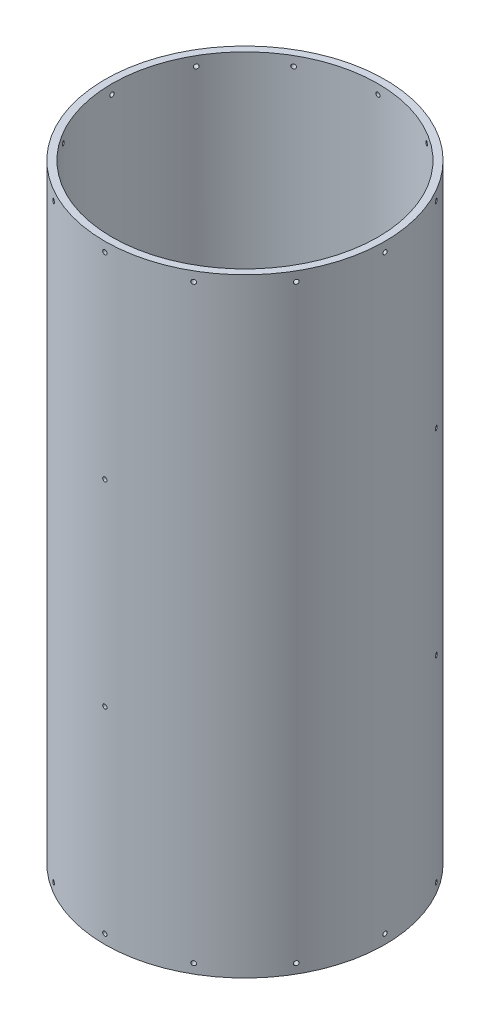
from build123d import *

# Parameters (mm, degrees)
SKETCH1_R                = 93.6625
SKETCH1_R_2              = 88.9
BOSS_EXTRUDE1_DEPTH      = 203.581
SKETCH3_R                = 1.4351
CUT_EXTRUDE1_DEPTH       = 19.304
CIRPATTERN1_COUNT        = 12
MIRROR1_COPY_1_SKETCH_R  = 1.4351
MIRROR1_COPY_1_DEPTH     = 19.304
MIRROR1_COPY_2_SKETCH_R  = 1.4351
MIRROR1_COPY_2_DEPTH     = 19.304
MIRROR1_COPY_3_SKETCH_R  = 1.4351
MIRROR1_COPY_3_DEPTH     = 19.304
MIRROR1_COPY_4_SKETCH_R  = 1.4351
MIRROR1_COPY_4_DEPTH     = 19.304
MIRROR1_COPY_5_SKETCH_R  = 1.4351
MIRROR1_COPY_5_DEPTH     = 19.304
MIRROR1_COPY_6_SKETCH_R  = 1.4351
MIRROR1_COPY_6_DEPTH     = 19.304
MIRROR1_COPY_7_SKETCH_R  = 1.4351
MIRROR1_COPY_7_DEPTH     = 19.304
MIRROR1_COPY_8_SKETCH_R  = 1.4351
MIRROR1_COPY_8_DEPTH     = 19.304
MIRROR1_COPY_9_SKETCH_R  = 1.4351
MIRROR1_COPY_9_DEPTH     = 19.304
MIRROR1_COPY_10_SKETCH_R = 1.4351
MIRROR1_COPY_10_DEPTH    = 19.304
MIRROR1_COPY_11_SKETCH_R = 1.4351
MIRROR1_COPY_11_DEPTH    = 19.304
SKETCH4_R                = 1.4351
CUT_EXTRUDE2_DEPTH       = 43.18
CIRPATTERN2_COUNT        = 3


with BuildPart() as part:
    # Sketch1 → Boss-Extrude1 (new body, symmetric)
    with BuildSketch(Plane(origin=(0, 0, 0), x_dir=(1, 0, 0), z_dir=(0, 1, 0))):
        Circle(SKETCH1_R)
        Circle(SKETCH1_R_2, mode=Mode.SUBTRACT)
    extrude(amount=BOSS_EXTRUDE1_DEPTH, both=True)

    # Sketch3 → Cut-Extrude1 (cut)
    with BuildSketch(Plane.XY.offset(93.6625)):
        with Locations((0, -197.231)):
            Circle(SKETCH3_R)
    cut_extrude1 = extrude(amount=-CUT_EXTRUDE1_DEPTH, mode=Mode.SUBTRACT)

    # CirPattern1: Cut-Extrude1 ×12 about axis
    cirpattern1_axis = Axis((0, 203.581, 0), (0, -1, 0))
    for i in range(1, CIRPATTERN1_COUNT):
        add(cut_extrude1.rotate(cirpattern1_axis, i * 360 / CIRPATTERN1_COUNT), mode=Mode.SUBTRACT)

    # Mirror1: Cut-Extrude1 across plane
    add(cut_extrude1.mirror(Plane.ZX), mode=Mode.SUBTRACT)

    # Mirror1 copy 1 sketch → Mirror1 copy 1 (cut)
    with BuildSketch(Plane(origin=(-46.83125, 0, 81.114104382), x_dir=(0.866025404, 0, 0.5), z_dir=(-0.5, 0, 0.866025404))):
        with Locations((0, 197.231)):
            Circle(MIRROR1_COPY_1_SKETCH_R)
    extrude(amount=-MIRROR1_COPY_1_DEPTH, mode=Mode.SUBTRACT)

    # Mirror1 copy 2 sketch → Mirror1 copy 2 (cut)
    with BuildSketch(Plane(origin=(-81.114104382, 0, 46.83125), x_dir=(0.5, 0, 0.866025404), z_dir=(-0.866025404, 0, 0.5))):
        with Locations((0, 197.231)):
            Circle(MIRROR1_COPY_2_SKETCH_R)
    extrude(amount=-MIRROR1_COPY_2_DEPTH, mode=Mode.SUBTRACT)

    # Mirror1 copy 3 sketch → Mirror1 copy 3 (cut)
    with BuildSketch(Plane.ZY.offset(93.6625)):
        with Locations((0, 197.231)):
            Circle(MIRROR1_COPY_3_SKETCH_R)
    extrude(amount=-MIRROR1_COPY_3_DEPTH, mode=Mode.SUBTRACT)

    # Mirror1 copy 4 sketch → Mirror1 copy 4 (cut)
    with BuildSketch(Plane(origin=(-81.114104382, 0, -46.83125), x_dir=(-0.5, 0, 0.866025404), z_dir=(-0.866025404, 0, -0.5))):
        with Locations((0, 197.231)):
            Circle(MIRROR1_COPY_4_SKETCH_R)
    extrude(amount=-MIRROR1_COPY_4_DEPTH, mode=Mode.SUBTRACT)

    # Mirror1 copy 5 sketch → Mirror1 copy 5 (cut)
    with BuildSketch(Plane(origin=(-46.83125, 0, -81.114104382), x_dir=(-0.866025404, 0, 0.5), z_dir=(-0.5, 0, -0.866025404))):
        with Locations((0, 197.231)):
            Circle(MIRROR1_COPY_5_SKETCH_R)
    extrude(amount=-MIRROR1_COPY_5_DEPTH, mode=Mode.SUBTRACT)

    # Mirror1 copy 6 sketch → Mirror1 copy 6 (cut)
    with BuildSketch(Plane(origin=(0, 0, -93.6625), x_dir=(-1, 0, 0), z_dir=(0, 0, -1))):
        with Locations((0, 197.231)):
            Circle(MIRROR1_COPY_6_SKETCH_R)
    extrude(amount=-MIRROR1_COPY_6_DEPTH, mode=Mode.SUBTRACT)

    # Mirror1 copy 7 sketch → Mirror1 copy 7 (cut)
    with BuildSketch(Plane(origin=(46.83125, 0, -81.114104382), x_dir=(-0.866025404, 0, -0.5), z_dir=(0.5, 0, -0.866025404))):
        with Locations((0, 197.231)):
            Circle(MIRROR1_COPY_7_SKETCH_R)
    extrude(amount=-MIRROR1_COPY_7_DEPTH, mode=Mode.SUBTRACT)

    # Mirror1 copy 8 sketch → Mirror1 copy 8 (cut)
    with BuildSketch(Plane(origin=(81.114104382, 0, -46.83125), x_dir=(-0.5, 0, -0.866025404), z_dir=(0.866025404, 0, -0.5))):
        with Locations((0, 197.231)):
            Circle(MIRROR1_COPY_8_SKETCH_R)
    extrude(amount=-MIRROR1_COPY_8_DEPTH, mode=Mode.SUBTRACT)

    # Mirror1 copy 9 sketch → Mirror1 copy 9 (cut)
    with BuildSketch(Plane(origin=(93.6625, 0, 0), x_dir=(0, 0, -1), z_dir=(1, 0, 0))):
        with Locations((0, 197.231)):
            Circle(MIRROR1_COPY_9_SKETCH_R)
    extrude(amount=-MIRROR1_COPY_9_DEPTH, mode=Mode.SUBTRACT)

    # Mirror1 copy 10 sketch → Mirror1 copy 10 (cut)
    with BuildSketch(Plane(origin=(81.114104382, 0, 46.83125), x_dir=(0.5, 0, -0.866025404), z_dir=(0.866025404, 0, 0.5))):
        with Locations((0, 197.231)):
            Circle(MIRROR1_COPY_10_SKETCH_R)
    extrude(amount=-MIRROR1_COPY_10_DEPTH, mode=Mode.SUBTRACT)

    # Mirror1 copy 11 sketch → Mirror1 copy 11 (cut)
    with BuildSketch(Plane(origin=(46.83125, 0, 81.114104382), x_dir=(0.866025404, 0, -0.5), z_dir=(0.5, 0, 0.866025404))):
        with Locations((0, 197.231)):
            Circle(MIRROR1_COPY_11_SKETCH_R)
    extrude(amount=-MIRROR1_COPY_11_DEPTH, mode=Mode.SUBTRACT)

    # Sketch4 → Cut-Extrude2 (cut)
    with BuildSketch(Plane.XY.offset(93.6625)):
        with Locations((0, 65.7606)):
            Circle(SKETCH4_R)
        with Locations((0, -65.7606)):
            Circle(SKETCH4_R)
    cut_extrude2 = extrude(amount=-CUT_EXTRUDE2_DEPTH, mode=Mode.SUBTRACT)

    # CirPattern2: Cut-Extrude2 ×3 about axis
    cirpattern2_axis = Axis((0, 203.581, 0), (0, -1, 0))
    for i in range(1, CIRPATTERN2_COUNT):
        add(cut_extrude2.rotate(cirpattern2_axis, i * 360 / CIRPATTERN2_COUNT), mode=Mode.SUBTRACT)


solid = part.part
